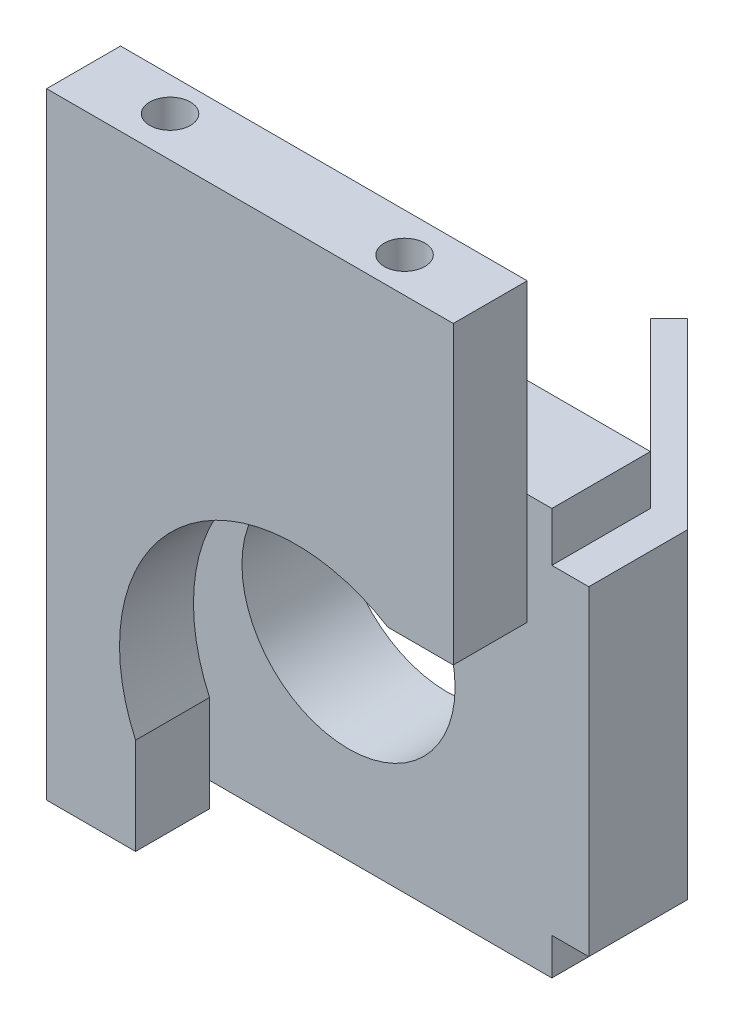
from build123d import *

# Parameters (mm, degrees)
SKETCH2_W           = 33
SKETCH2_H           = 33
SKETCH2_R           = 8.65
BOSS_EXTRUDE1_DEPTH = 8
SKETCH3_W           = 8
SKETCH3_H           = 26
BOSS_EXTRUDE2_DEPTH = 3
SKETCH4_W           = 26
SKETCH4_H           = 21
SKETCH4_R           = 8.1
BOSS_EXTRUDE3_DEPTH = 2.12
SKETCH5_R           = 1.5
BOSS_EXTRUDE4_DEPTH = 2
BOSS_EXTRUDE5_DEPTH = 6
SKETCH7_R           = 1.65
CUT_EXTRUDE1_DEPTH  = 10


with BuildPart() as part:
    # Sketch2 → Boss-Extrude1 (new body)
    with BuildSketch(Plane.XY):
        with Locations((16.5, 16.5)):
            Rectangle(SKETCH2_W, SKETCH2_H)
        with Locations((16.5, 16.5)):
            Circle(SKETCH2_R, mode=Mode.SUBTRACT)
    extrude(amount=BOSS_EXTRUDE1_DEPTH)

    # Sketch3 → Boss-Extrude2 (add)
    with BuildSketch(Plane(origin=(33, 0, 0), x_dir=(0, 0, -1), z_dir=(1, 0, 0))):
        with Locations((-4, 16)):
            Rectangle(SKETCH3_W, SKETCH3_H)
    extrude(amount=BOSS_EXTRUDE2_DEPTH)

    # Sketch4 → Boss-Extrude3 (add)
    with BuildSketch(Plane(origin=(16.5, 0, -16.5), x_dir=(0, 1, 0), z_dir=(0.707106781, 0, -0.707106781))):
        with Locations((16, 14.955844123)):
            Rectangle(SKETCH4_W, SKETCH4_H)
        with Locations((16, 14.955844123)):
            Circle(SKETCH4_R, mode=Mode.SUBTRACT)
    extrude(amount=BOSS_EXTRUDE3_DEPTH)

    # Sketch5 → Boss-Extrude4 (add)
    with BuildSketch(Plane.XY.offset(8)):
        with Locations((2.5, 30.5)):
            Circle(SKETCH5_R)
    extrude(amount=BOSS_EXTRUDE4_DEPTH)

    # Sketch6 → Boss-Extrude5 (add)
    with BuildSketch(Plane.XY.offset(10)):
        with BuildLine():
            Line((7.22, 0), (7.22, 7.823187296))
            ThreePointArc((7.22, 7.823187296), (10.728461041, 24.490588089), (27.694109386, 26))
            Line((27.694109386, 26), (33, 26))
            Line((33, 26), (33, 50))
            Line((33, 50), (0, 50))
            Line((0, 50), (0, 0))
            Line((0, 0), (7.22, 0))
        make_face()
    extrude(amount=BOSS_EXTRUDE5_DEPTH)

    # Sketch7 → Cut-Extrude1 (cut)
    with BuildSketch(Plane(origin=(0, 50, 0), x_dir=(1, 0, 0), z_dir=(0, 1, 0))):
        with Locations((6.77, -12.75)):
            Circle(SKETCH7_R)
        with Locations((26.2, -13.15)):
            Circle(SKETCH7_R)
    extrude(amount=-CUT_EXTRUDE1_DEPTH, mode=Mode.SUBTRACT)


solid = part.part
